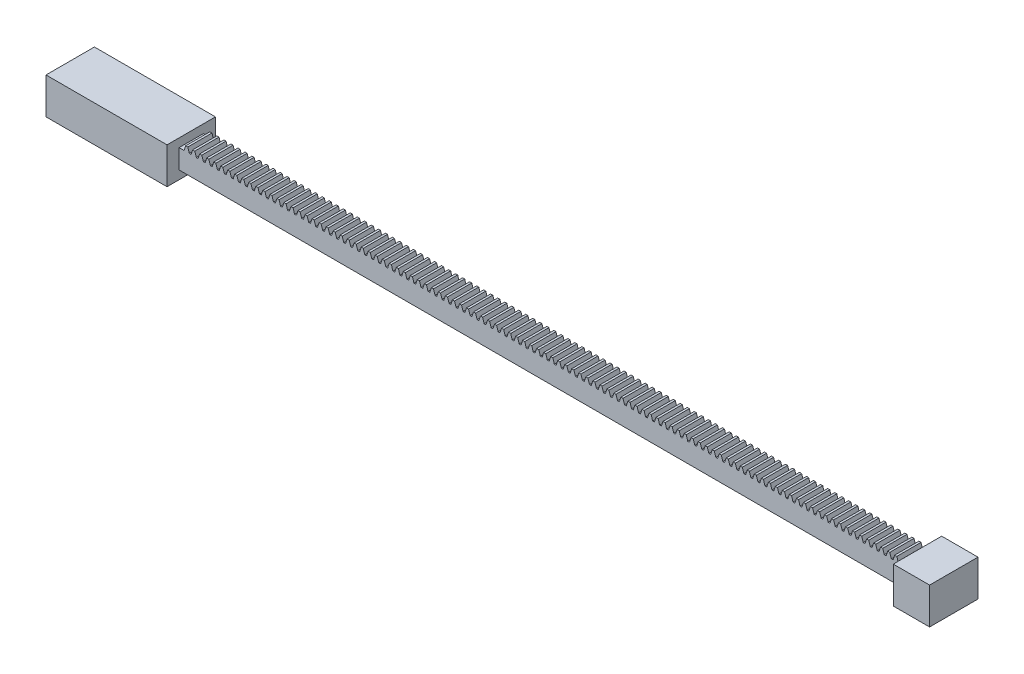
from build123d import *

# Parameters (mm, degrees)
SKETCH1_W           = 300
SKETCH1_H           = 8
BOSS_EXTRUDE1_DEPTH = 10
BOSS_EXTRUDE2_DEPTH = 10
LPATTERN1_COUNT     = 103
LPATTERN1_PITCH     = 2.9
SKETCH3_W           = 20
SKETCH3_H           = 15
BOSS_EXTRUDE3_DEPTH = 15
SKETCH4_W           = 20
SKETCH4_H           = 15
BOSS_EXTRUDE4_DEPTH = 50


with BuildPart() as part:
    # Sketch1 → Boss-Extrude1 (new body)
    with BuildSketch(Plane.XY):
        Rectangle(SKETCH1_W, SKETCH1_H)
    extrude(amount=BOSS_EXTRUDE1_DEPTH)

    # Sketch2 → Boss-Extrude2 (add)
    with BuildSketch(Plane.XY.offset(10)):
        Polygon((147.839375153, 4), (148.479687576, 6), (149.359687576, 6), (150, 4), align=None)
    boss_extrude2 = extrude(amount=-BOSS_EXTRUDE2_DEPTH)

    # LPattern1: Boss-Extrude2 ×103
    with Locations(*[(-i * LPATTERN1_PITCH, 0, 0) for i in range(1, LPATTERN1_COUNT)]):
        add(boss_extrude2)

    # Sketch3 → Boss-Extrude3 (add)
    with BuildSketch(Plane(origin=(150, 0, 0), x_dir=(0, 0, -1), z_dir=(1, 0, 0))):
        with Locations((-5, 0)):
            Rectangle(SKETCH3_W, SKETCH3_H)
    extrude(amount=BOSS_EXTRUDE3_DEPTH)

    # Sketch4 → Boss-Extrude4 (add)
    with BuildSketch(Plane.ZY.offset(150)):
        with Locations((5, 0)):
            Rectangle(SKETCH4_W, SKETCH4_H)
    extrude(amount=BOSS_EXTRUDE4_DEPTH)


solid = part.part
